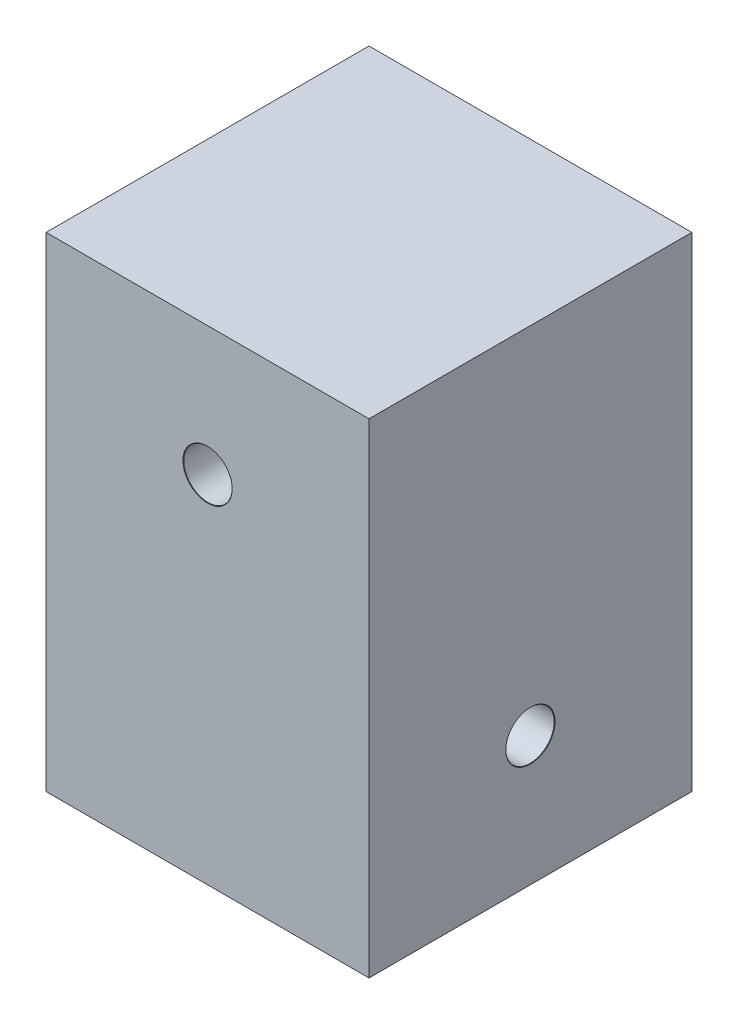
from build123d import *

# Parameters (mm, degrees)
SKETCH1_W                       = 20
SKETCH1_H                       = 20
BOSS_EXTRUDE1_DEPTH             = 30
F_3_0MM_DOWEL_HOLE1_D           = 3
F_3_0MM_DOWEL_HOLE1_DEPTH       = 20
F_3_0MM_DOWEL_HOLE1_CSINK_D     = 3.05
F_3_0MM_DOWEL_HOLE1_CSINK_ANGLE = 90
F_3_0MM_DOWEL_HOLE1_TIP         = 0.901290929
F_3_0MM_DOWEL_HOLE2_D           = 3
F_3_0MM_DOWEL_HOLE2_DEPTH       = 20
F_3_0MM_DOWEL_HOLE2_CSINK_D     = 3.05
F_3_0MM_DOWEL_HOLE2_CSINK_ANGLE = 90
F_3_0MM_DOWEL_HOLE2_TIP         = 0.901290929


with BuildPart() as part:
    # Sketch1 → Boss-Extrude1 (new body)
    with BuildSketch(Plane(origin=(0, 0, 0), x_dir=(1, 0, 0), z_dir=(0, 1, 0))):
        with Locations((10, -10)):
            Rectangle(SKETCH1_W, SKETCH1_H)
    extrude(amount=BOSS_EXTRUDE1_DEPTH)

    # Ø3.0mm Dowel Hole1
    with Locations(Plane(origin=(20, 0, 0), x_dir=(0, 0, -1), z_dir=(1, 0, 0))):
        with Locations((-10, 8)):
            CounterSinkHole(F_3_0MM_DOWEL_HOLE1_D / 2, F_3_0MM_DOWEL_HOLE1_CSINK_D / 2, depth=F_3_0MM_DOWEL_HOLE1_DEPTH, counter_sink_angle=F_3_0MM_DOWEL_HOLE1_CSINK_ANGLE)
            with Locations((0, 0, -(F_3_0MM_DOWEL_HOLE1_DEPTH + F_3_0MM_DOWEL_HOLE1_TIP / 2))):  # 118° drill point
                Cone(0, F_3_0MM_DOWEL_HOLE1_D / 2, F_3_0MM_DOWEL_HOLE1_TIP, mode=Mode.SUBTRACT)

    # Ø3.0mm Dowel Hole2
    with Locations(Plane.XY.offset(20)):
        with Locations((10, 22)):
            CounterSinkHole(F_3_0MM_DOWEL_HOLE2_D / 2, F_3_0MM_DOWEL_HOLE2_CSINK_D / 2, depth=F_3_0MM_DOWEL_HOLE2_DEPTH, counter_sink_angle=F_3_0MM_DOWEL_HOLE2_CSINK_ANGLE)
            with Locations((0, 0, -(F_3_0MM_DOWEL_HOLE2_DEPTH + F_3_0MM_DOWEL_HOLE2_TIP / 2))):  # 118° drill point
                Cone(0, F_3_0MM_DOWEL_HOLE2_D / 2, F_3_0MM_DOWEL_HOLE2_TIP, mode=Mode.SUBTRACT)


solid = part.part
